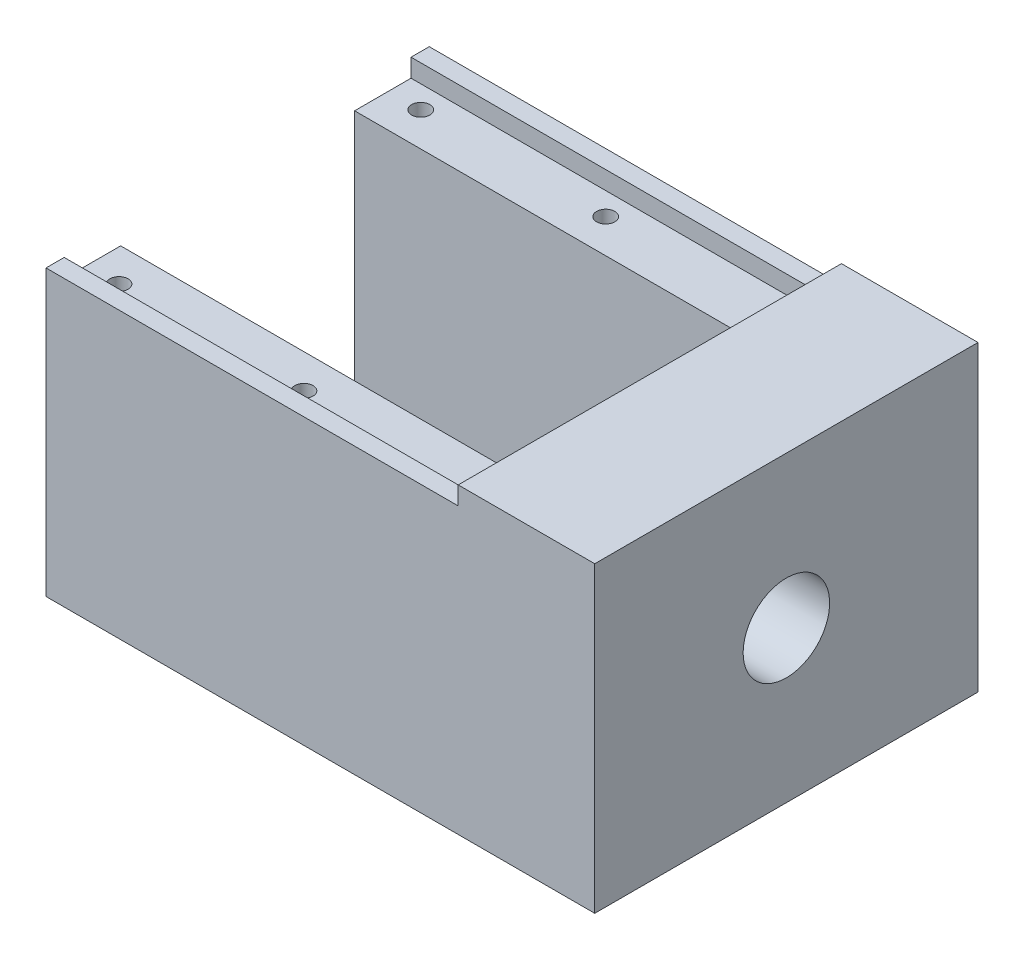
from build123d import *

# Parameters (mm, degrees)
SKETCH1_W                      = 59.28
SKETCH1_H                      = 38.1
BOSS_EXTRUDE2_DEPTH            = 29.26
SKETCH2_W                      = 15
SKETCH2_H                      = 38.1
BOSS_EXTRUDE3_DEPTH            = 4
SKETCH4_W                      = 44.28
SKETCH4_H                      = 25.7
CUT_EXTRUDE7_DEPTH             = 27.26
SKETCH7_R                      = 4.75
SKETCH8_R                      = 4.807692308
BOSS_EXTRUDE4_DEPTH            = 2
BOSS_EXTRUDE5_DEPTH            = 2
SKETCH15_W                     = 44.28
SKETCH15_H                     = 2
CUT_EXTRUDE9_DEPTH             = 2
BOSS_EXTRUDE6_DEPTH            = 1
F_2_0MM_DOWEL_HOLE1_AT_2_COUNT = 2
F_2_0MM_DOWEL_HOLE1_AT_2_PITCH = 20.32
LPATTERN1_COUNT                = 2
LPATTERN1_PITCH                = 33.15
SKETCH20_W                     = 25.7
SKETCH20_H                     = 27.26
SKETCH20_W_2                   = 14
SKETCH20_H_2                   = 14
CUT_EXTRUDE10_DEPTH            = 11


with BuildPart() as part:
    # Sketch1 → Boss-Extrude2 (new body)
    with BuildSketch(Plane(origin=(0, 0, 0), x_dir=(1, 0, 0), z_dir=(0, 1, 0))):
        with Locations((29.64, 19.05)):
            Rectangle(SKETCH1_W, SKETCH1_H)
    extrude(amount=BOSS_EXTRUDE2_DEPTH)

    # Sketch2 → Boss-Extrude3 (add)
    with BuildSketch(Plane(origin=(0, 29.26, 0), x_dir=(1, 0, 0), z_dir=(0, 1, 0))):
        with Locations((51.78, 19.05)):
            Rectangle(SKETCH2_W, SKETCH2_H)
    extrude(amount=BOSS_EXTRUDE3_DEPTH)

    # Sketch4 → Cut-Extrude7 (cut)
    with BuildSketch(Plane(origin=(0, 29.26, 0), x_dir=(1, 0, 0), z_dir=(0, 1, 0))):
        with Locations((22.14, 19.05)):
            Rectangle(SKETCH4_W, SKETCH4_H)
    extrude(amount=-CUT_EXTRUDE7_DEPTH, mode=Mode.SUBTRACT)

    # Sketch7 → Cut-Loft2 section 0
    with BuildSketch(Plane(origin=(59.28, 0, 0), x_dir=(0, 0, -1), z_dir=(1, 0, 0))):
        with Locations((19.05, 16.63)):
            Circle(SKETCH7_R)
    # Sketch8 → Cut-Loft2 section 1
    with BuildSketch(Plane.ZY.offset(-44.28)):
        with Locations((-19.05, 16.556791368)):
            Circle(SKETCH8_R)
    loft(mode=Mode.SUBTRACT)

    # Sketch13 → Boss-Extrude4 (add)
    with BuildSketch(Plane.XY):
        Polygon((0, 29.26), (0, 0), (59.28, 0), (59.28, 29.26), (59.28, 33.26), (0, 33.26), align=None)
    extrude(amount=BOSS_EXTRUDE4_DEPTH)

    # Sketch14 → Boss-Extrude5 (add)
    with BuildSketch(Plane(origin=(0, 0, -38.1), x_dir=(-1, 0, 0), z_dir=(0, 0, -1))):
        Polygon((-59.28, 0), (0, 0), (0, 29.26), (0, 33.26), (-59.28, 33.26), (-59.28, 29.26), align=None)
    extrude(amount=BOSS_EXTRUDE5_DEPTH)

    # Sketch15 → Cut-Extrude9 (cut)
    with BuildSketch(Plane(origin=(0, 33.26, 0), x_dir=(1, 0, 0), z_dir=(0, 1, 0))):
        with Locations((22.14, -1)):
            Rectangle(SKETCH15_W, SKETCH15_H)
        with Locations((22.14, 39.1)):
            Rectangle(SKETCH15_W, SKETCH15_H)
    extrude(amount=-CUT_EXTRUDE9_DEPTH, mode=Mode.SUBTRACT)

    # Sketch16 → Boss-Extrude6 (add)
    with BuildSketch(Plane.ZY):
        Polygon((-40.1, 31.26), (-38.1, 31.26), (-38.1, 29.26), (-31.9, 29.26), (-31.9, 2), (-6.2, 2), (-6.2, 29.26), (0, 29.26), (0, 31.26), (2, 31.26), (2, 0), (-40.1, 0), align=None)
    extrude(amount=BOSS_EXTRUDE6_DEPTH)

    # Sketch18 → Ø2.0mm Dowel Hole1 (revolve, cut)
    with BuildSketch(Plane(origin=(2.54, 29.26, -2.475), x_dir=(0, 0, 1), z_dir=(1, 0, 0))):
        Polygon((0, 0), (0, 20.600860619), (1, 20), (1, 0), align=None)
    f_2_0mm_dowel_hole1 = revolve(axis=Axis((2.54, 35.61, -2.475), (0, -1, 0)), mode=Mode.SUBTRACT)

    # Ø2.0mm Dowel Hole1 at 2: Ø2.0mm Dowel Hole1 ×2
    with Locations(*[(i * F_2_0MM_DOWEL_HOLE1_AT_2_PITCH, 0, 0) for i in range(1, F_2_0MM_DOWEL_HOLE1_AT_2_COUNT)]):
        add(f_2_0mm_dowel_hole1, mode=Mode.SUBTRACT)

    # LPattern1: Ø2.0mm Dowel Hole1 ×2
    with Locations(*[(0, 0, -i * LPATTERN1_PITCH) for i in range(1, LPATTERN1_COUNT)]):
        add(f_2_0mm_dowel_hole1, mode=Mode.SUBTRACT)

    # LPattern1 copy 1 sketch → LPattern1 copy 1 (revolve, cut)
    with BuildSketch(Plane(origin=(22.86, 29.26, -35.625), x_dir=(0, 0, 1), z_dir=(1, 0, 0))):
        Polygon((0, 0), (0, 20.600860619), (1, 20), (1, 0), align=None)
    revolve(axis=Axis((22.86, 35.61, -35.625), (0, -1, 0)), mode=Mode.SUBTRACT)

    # Sketch20 → Cut-Extrude10 (cut)
    with BuildSketch(Plane.ZY.offset(-44.28)):
        with Locations((-19.05, 15.63)):
            Rectangle(SKETCH20_W, SKETCH20_H)
        with Locations((-19.05, 16.716836028)):
            Rectangle(SKETCH20_W_2, SKETCH20_H_2, mode=Mode.SUBTRACT)
    extrude(amount=-CUT_EXTRUDE10_DEPTH, mode=Mode.SUBTRACT)


solid = part.part
